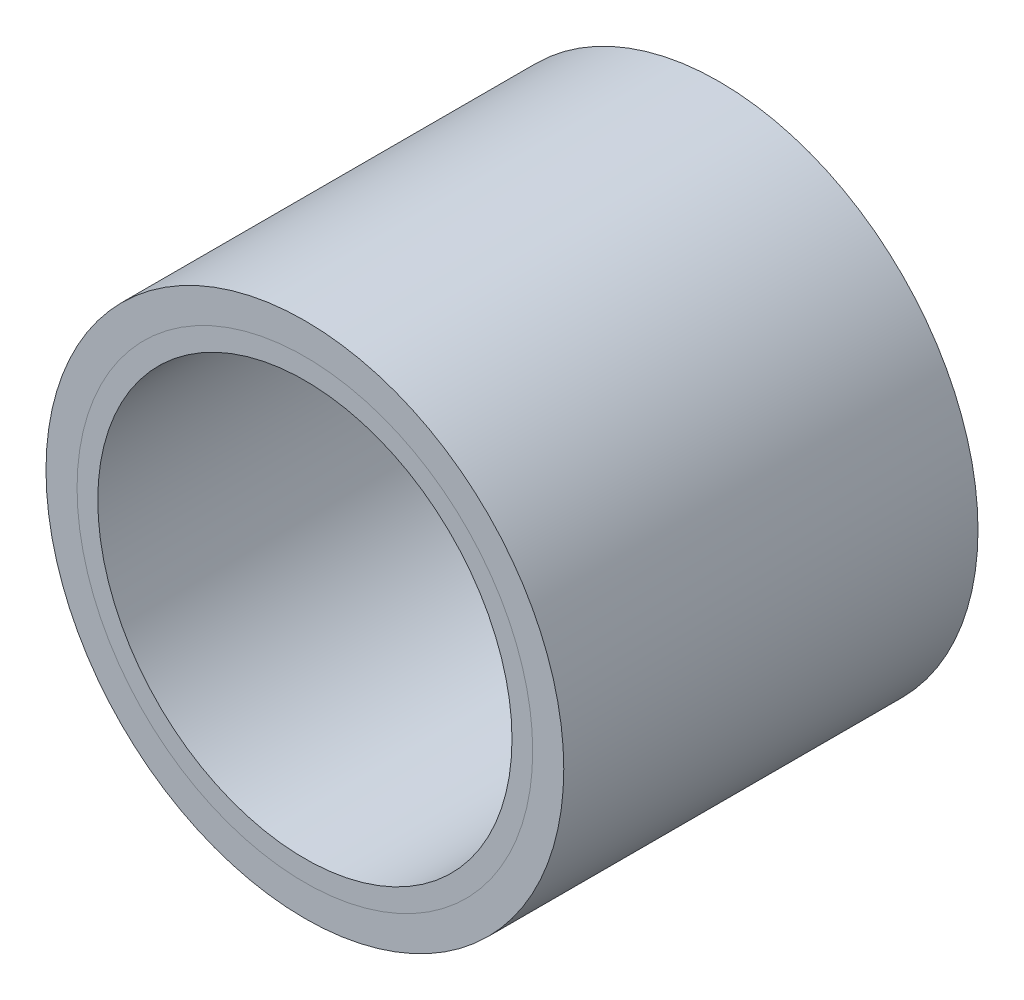
from build123d import *

# Parameters (mm, degrees)
SKETCH2_R           = 11
SKETCH2_R_2         = 10
BOSS_EXTRUDE1_DEPTH = 10
SKETCH3_R           = 12.5
SKETCH3_R_2         = 11
BOSS_EXTRUDE2_DEPTH = 20


with BuildPart() as part:
    # Sketch2 → Boss-Extrude1 (new body, symmetric)
    with BuildSketch(Plane.XY):
        Circle(SKETCH2_R)
        Circle(SKETCH2_R_2, mode=Mode.SUBTRACT)
    extrude(amount=BOSS_EXTRUDE1_DEPTH, both=True)


with BuildPart() as body_2:
    # Sketch3 → Boss-Extrude2 (new body, through all)
    with BuildSketch(Plane.XY.offset(10)):
        Circle(SKETCH3_R)
        Circle(SKETCH3_R_2, mode=Mode.SUBTRACT)
    extrude(amount=-BOSS_EXTRUDE2_DEPTH)


solid = Compound([part.part, body_2.part])
